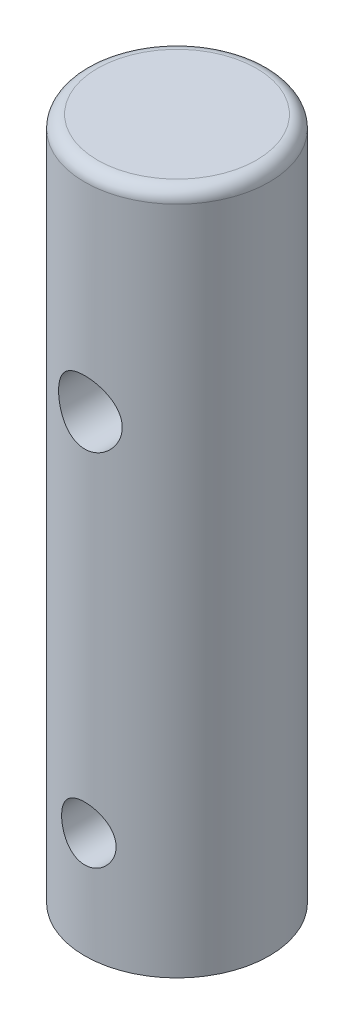
from build123d import *

# Parameters (mm, degrees)
SKETCH1_R               = 5.5245
BOSS_EXTRUDE1_DEPTH     = 40.894
SKETCH2_R               = 1.905
SKETCH2_R_2             = 1.63195
CUT_EXTRUDE1_DEPTH      = 6.5245
CUT_EXTRUDE1_DEPTH_BACK = 6.5245
FILLET1_R               = 0.762


with BuildPart() as part:
    # Sketch1 → Boss-Extrude1 (new body)
    with BuildSketch(Plane(origin=(0, 0, 0), x_dir=(1, 0, 0), z_dir=(0, 1, 0))):
        Circle(SKETCH1_R)
    extrude(amount=BOSS_EXTRUDE1_DEPTH)

    # Sketch2 → Cut-Extrude1 (cut, two sides)
    with BuildSketch(Plane.XY) as cut_extrude1_sk:
        with Locations((0, 28.194)):
            Circle(SKETCH2_R)
        with Locations((0, 6.35)):
            Circle(SKETCH2_R_2)
    extrude(amount=CUT_EXTRUDE1_DEPTH, mode=Mode.SUBTRACT)
    extrude(cut_extrude1_sk.sketch, amount=-CUT_EXTRUDE1_DEPTH_BACK, mode=Mode.SUBTRACT)

    # Fillet1
    fillet1_edges = [part.edges().sort_by_distance(p)[0] for p in [
        (-5.5245, 40.894, 0),
    ]]
    fillet(fillet1_edges, radius=FILLET1_R)


solid = part.part
